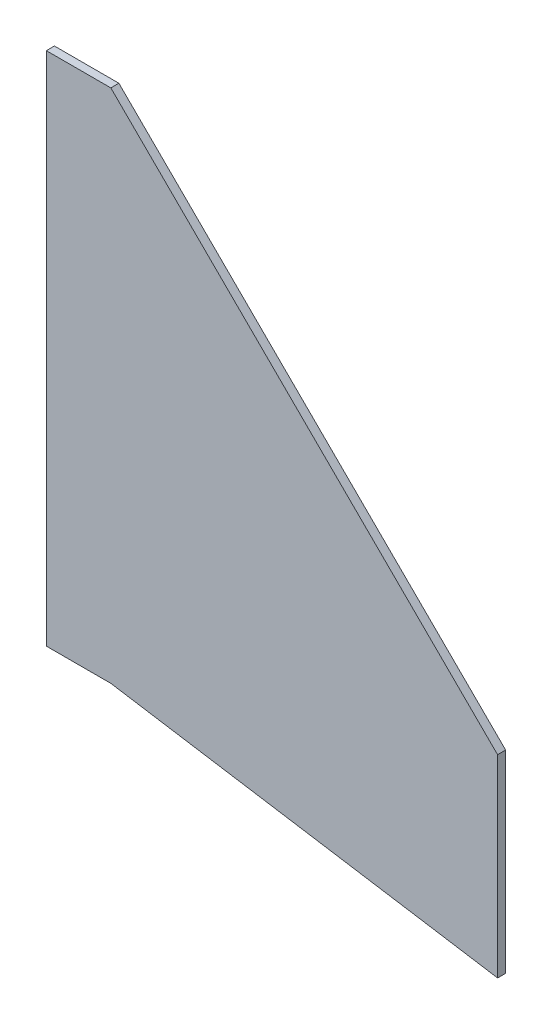
from build123d import *

# Parameters (mm, degrees)
SKETCH1_W           = 25.4
SKETCH1_H           = 203.2
BOSS_EXTRUDE1_DEPTH = 1.5875


with BuildPart() as part:
    # Sketch1 → Boss-Extrude1 (new body, symmetric)
    with BuildSketch(Plane.XY):
        with Locations((-12.7, -101.6)):
            Rectangle(SKETCH1_W, SKETCH1_H)
        Polygon((152.4, -227.539743973), (152.4, -151.339743973), (0, 0), (0, -203.2), align=None)
    extrude(amount=BOSS_EXTRUDE1_DEPTH, both=True)


solid = part.part
